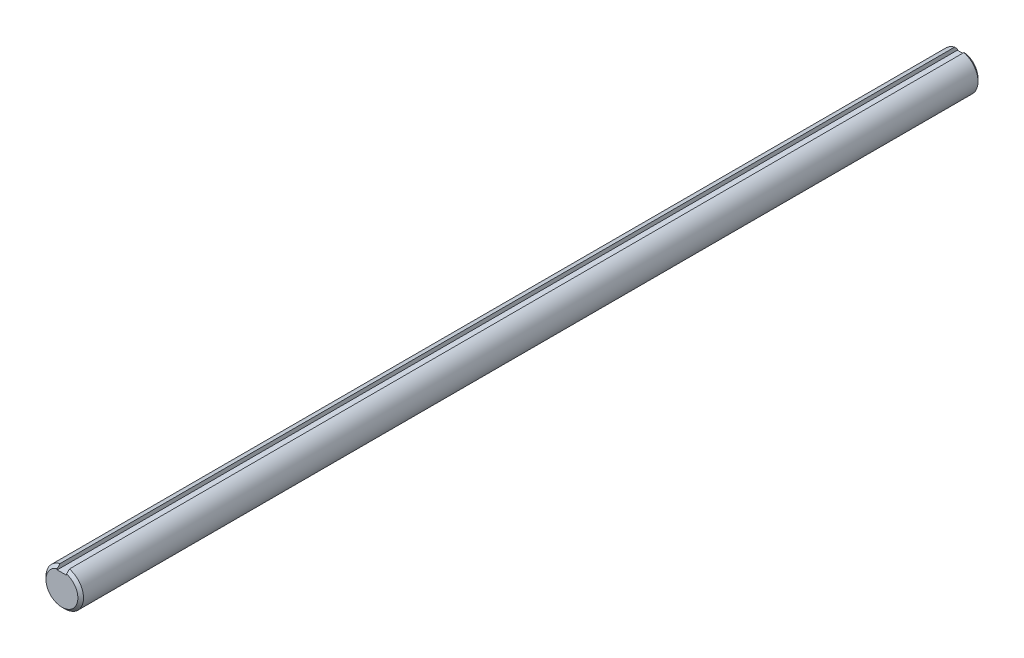
from build123d import *

# Parameters (mm, degrees)
SKETCH1_R           = 6.35
EXTRUDE1_DEPTH      = 152.4
CHAMFER1_SIZE       = 0.9525
SKETCH3_W           = 3.175
SKETCH3_H           = 1.5875
EXTRUDE2_DEPTH      = 153.4
EXTRUDE2_DEPTH_BACK = 153.4


with BuildPart() as part:
    # Sketch1 → Extrude1 (new body, symmetric)
    with BuildSketch(Plane.XY):
        Circle(SKETCH1_R)
    extrude(amount=EXTRUDE1_DEPTH, both=True)

    # Chamfer1
    chamfer1_edges = [part.edges().sort_by_distance(p)[0] for p in [
        (-6.35, 0, -152.4),
        (-6.35, 0, 152.4),
    ]]
    chamfer(chamfer1_edges, length=CHAMFER1_SIZE)

    # Sketch3 → Extrude2 (cut, two sides)
    with BuildSketch(Plane.XY) as extrude2_sk:
        with Locations((0, 5.55625)):
            Rectangle(SKETCH3_W, SKETCH3_H)
    extrude(amount=EXTRUDE2_DEPTH, mode=Mode.SUBTRACT)
    extrude(extrude2_sk.sketch, amount=-EXTRUDE2_DEPTH_BACK, mode=Mode.SUBTRACT)


solid = part.part
